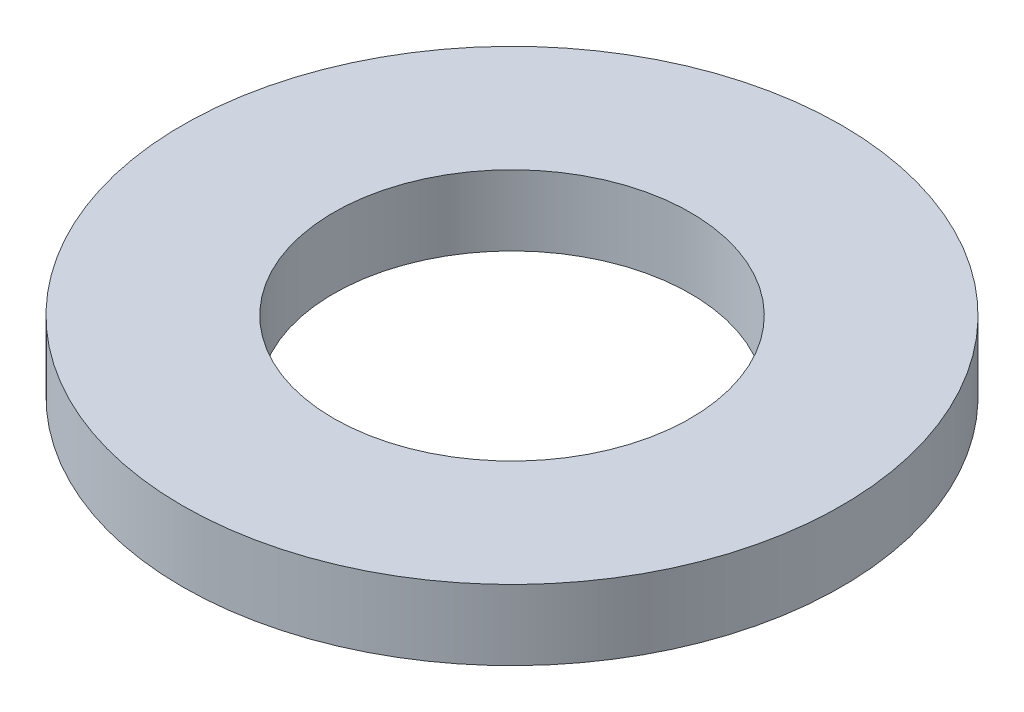
from build123d import *

# Parameters (mm, degrees)
SKETCH1_R           = 9.525
BOSS_EXTRUDE1_DEPTH = 2.032
SKETCH5_R           = 5.1562
CUT_EXTRUDE1_DEPTH  = 3.032


with BuildPart() as part:
    # Sketch1 → Boss-Extrude1 (new body)
    with BuildSketch(Plane(origin=(0, 0, 0), x_dir=(1, 0, 0), z_dir=(0, 1, 0))):
        Circle(SKETCH1_R)
    extrude(amount=BOSS_EXTRUDE1_DEPTH)

    # Sketch5 → Cut-Extrude1 (cut, through all)
    with BuildSketch(Plane(origin=(0, 2.032, 0), x_dir=(-1, 0, 0), z_dir=(0, 1, 0))):
        Circle(SKETCH5_R)
    extrude(amount=-CUT_EXTRUDE1_DEPTH, mode=Mode.SUBTRACT)


solid = part.part
